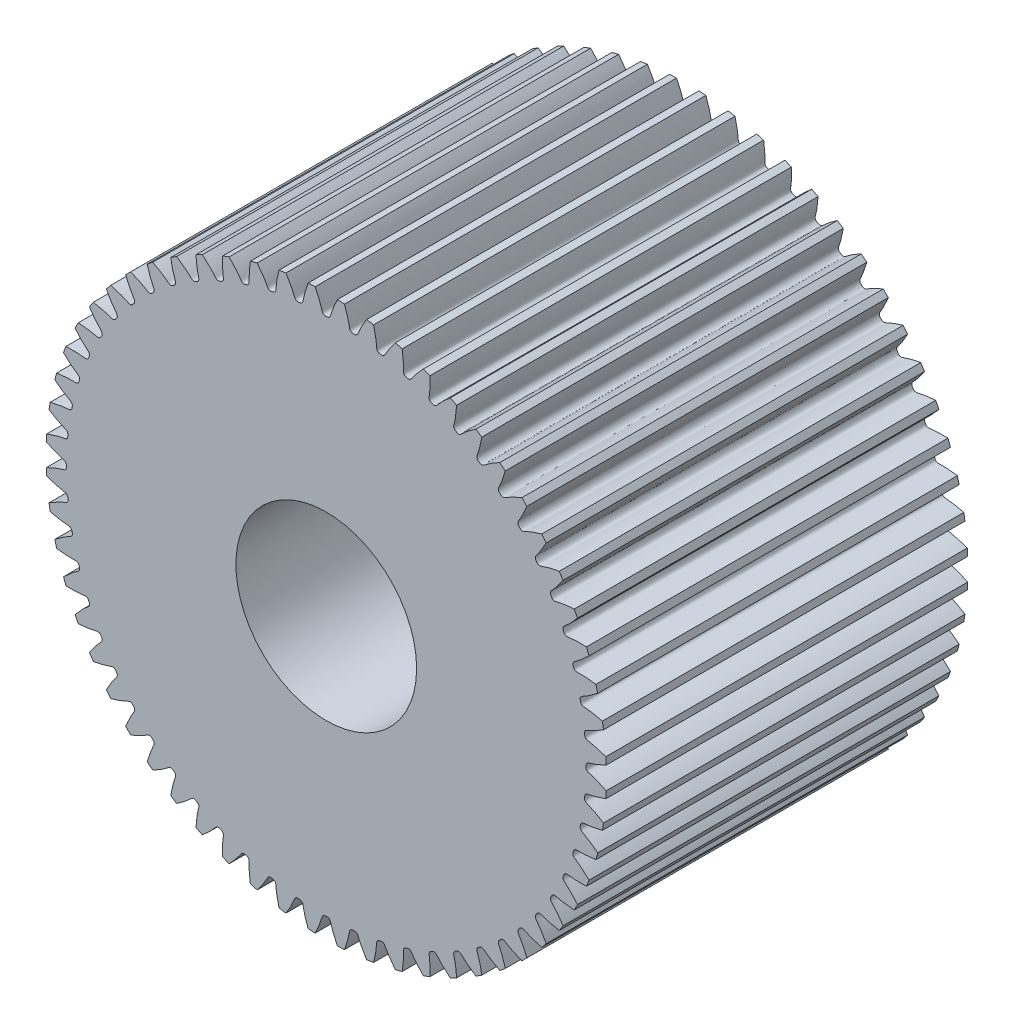
from build123d import *

# Parameters (mm, degrees)
SKETCHREVOLVESPURGEAR2_W       = 20
SKETCHREVOLVESPURGEAR2_H       = 15.499999767
TOOTHEXTRUDECUTSPURGEAR2_DEPTH = 10
PATTERNSPURGEAR2_COUNT         = 60
BOREREVOLVESKETCH_W            = 20
BOREREVOLVESKETCH_H            = 5


with BuildPart() as part:
    # SketchRevolveSpurGear2 → SpurGear2 (revolve)
    with BuildSketch(Plane(origin=(0, 0, 0), x_dir=(0, 0, -1), z_dir=(1, 0, 0))):
        with Locations((0, 7.749999884)):
            Rectangle(SKETCHREVOLVESPURGEAR2_W, SKETCHREVOLVESPURGEAR2_H)
    revolve(axis=Axis((0, 0, 0), (0, 0, -1)))

    # SketchToothSpurGear2 → ToothExtrudeCutSpurGear2 (cut, symmetric)
    with BuildSketch(Plane.XY):
        with BuildLine():
            ThreePointArc((15.512313963, 0.627481699), (15.524999767, 0), (15.512313963, -0.627481699))
            add(Edge.make_bspline(
                [(15.512313963, -0.627481699), (15.470193591, -0.605930108), (15.407448616, -0.574683215), (15.32415719, -0.534954025), (15.26375607, -0.506967493), (15.204651836, -0.48038004), (15.146868016, -0.455159095), (15.090427571, -0.431271732), (15.035352888, -0.40868469), (14.981665787, -0.387364355), (14.929387474, -0.367276868), (14.878538677, -0.348387785), (14.829139159, -0.330663312), (14.781209421, -0.314065967), (14.734764632, -0.298570013), (14.689836117, -0.284106862), (14.646395426, -0.270757941), (14.585121431, -0.2521545), (14.5303874, -0.239512562), (14.485644434, -0.22013724), (14.465659344, -0.20946999), (14.444420746, -0.195201636), (14.421576792, -0.174964158), (14.398318827, -0.14537653), (14.380003302, -0.105133827), (14.373032545, -0.054503387), (14.376071476, 0), (14.373032545, 0.054503387), (14.380003302, 0.105133827), (14.398318827, 0.14537653), (14.421576792, 0.174964158), (14.444420746, 0.195201636), (14.465659344, 0.20946999), (14.485644434, 0.22013724), (14.5303874, 0.239512562), (14.585121431, 0.2521545), (14.646395426, 0.270757941), (14.689836117, 0.284106862), (14.734764632, 0.298570013), (14.781209421, 0.314065967), (14.829139159, 0.330663312), (14.878538677, 0.348387785), (14.929387474, 0.367276868), (14.981665787, 0.387364355), (15.035352888, 0.40868469), (15.090427571, 0.431271732), (15.146868016, 0.455159095), (15.204651836, 0.48038004), (15.26375607, 0.506967493), (15.32415719, 0.534954025), (15.407448616, 0.574683215), (15.470193591, 0.605930108), (15.512313963, 0.627481699)],
                knots=[0, 0, 0, 0, 0.05176586, 0.076685537, 0.100963046, 0.124598386, 0.147591557, 0.16994256, 0.191651394, 0.21271806, 0.233142557, 0.252924885, 0.272065045, 0.290563036, 0.308418859, 0.325632513, 0.342203998, 0.358133315, 0.395728589, 0.403326908, 0.411414611, 0.420483419, 0.431260975, 0.444674611, 0.46138654, 0.478964563, 0.5, 0.521035437, 0.53861346, 0.555325389, 0.568739025, 0.579516581, 0.588585389, 0.596673092, 0.604271411, 0.641866685, 0.657796002, 0.674367487, 0.691581141, 0.709436964, 0.727934955, 0.747075115, 0.766857443, 0.78728194, 0.808348606, 0.83005744, 0.852408443, 0.875401614, 0.899036954, 0.923314463, 0.94823414, 1, 1, 1, 1], degree=3))
        make_face()
    toothextrudecutspurgear2 = extrude(amount=TOOTHEXTRUDECUTSPURGEAR2_DEPTH, both=True, mode=Mode.SUBTRACT)

    # PatternSpurGear2: ToothExtrudeCutSpurGear2 ×60 about axis
    patternspurgear2_axis = Axis((0, 0, 55), (0, 0, -1))
    for i in range(1, PATTERNSPURGEAR2_COUNT):
        add(toothextrudecutspurgear2.rotate(patternspurgear2_axis, i * 360 / PATTERNSPURGEAR2_COUNT), mode=Mode.SUBTRACT)

    # BoreRevolveSketch → BoreRevolveCut (revolve, cut)
    with BuildSketch(Plane(origin=(0, 0, 0), x_dir=(0, 0, -1), z_dir=(1, 0, 0))):
        with Locations((0, 2.5)):
            Rectangle(BOREREVOLVESKETCH_W, BOREREVOLVESKETCH_H)
    revolve(axis=Axis((0, 0, 0), (0, 0, -1)), mode=Mode.SUBTRACT)


solid = part.part
